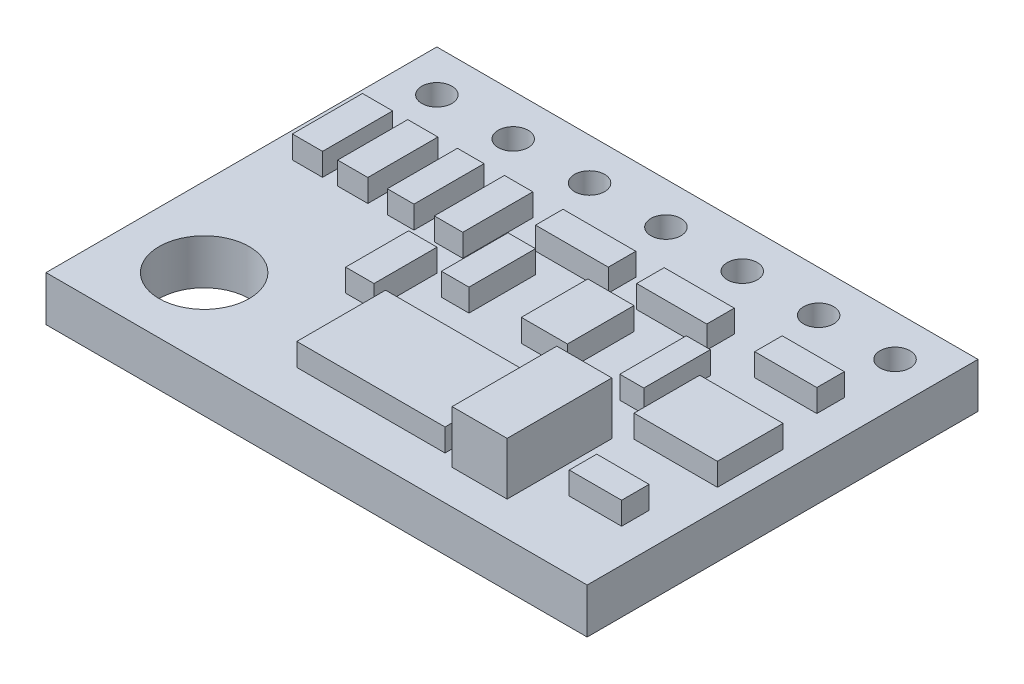
from build123d import *

# Parameters (mm, degrees)
SKETCH1_W           = 18
SKETCH1_H           = 13
SKETCH1_R           = 0.5
SKETCH1_R_2         = 1.5
BOSS_EXTRUDE1_DEPTH = 1.5
SKETCH2_W           = 1.829914293
SKETCH2_H           = 3.482740107
BOSS_EXTRUDE2_DEPTH = 1.75
SKETCH3_W           = 4.928962693
SKETCH3_H           = 2.951474666
SKETCH3_W_2         = 1.003501387
SKETCH3_H_2         = 2.331664987
SKETCH3_W_3         = 0.8854424
SKETCH3_W_4         = 0.944471893
SKETCH3_H_3         = 2.095547014
SKETCH3_W_5         = 0.914957147
SKETCH3_H_4         = 2.213606
SKETCH3_W_6         = 2.420209226
SKETCH3_H_5         = 0.914957147
SKETCH3_W_7         = 2.331664986
SKETCH3_W_8         = 2.066032267
SKETCH3_W_9         = 0.79689816
SKETCH3_W_10        = 2.774386186
SKETCH3_H_6         = 2.184091253
SKETCH3_W_11        = 1.741370054
SKETCH3_W_12        = 1.534766827
BOSS_EXTRUDE3_DEPTH = 0.75


with BuildPart() as part:
    # Sketch1 → Boss-Extrude1 (new body)
    with BuildSketch(Plane(origin=(0, 0, 0), x_dir=(1, 0, 0), z_dir=(0, 1, 0))):
        with Locations((9, -6.5)):
            Rectangle(SKETCH1_W, SKETCH1_H)
        with Locations((1.38, -1.38)):
            Circle(SKETCH1_R, mode=Mode.SUBTRACT)
        with Locations((3.92, -1.38)):
            Circle(SKETCH1_R, mode=Mode.SUBTRACT)
        with Locations((6.46, -1.38)):
            Circle(SKETCH1_R, mode=Mode.SUBTRACT)
        with Locations((9, -1.38)):
            Circle(SKETCH1_R, mode=Mode.SUBTRACT)
        with Locations((11.54, -1.38)):
            Circle(SKETCH1_R, mode=Mode.SUBTRACT)
        with Locations((14.08, -1.38)):
            Circle(SKETCH1_R, mode=Mode.SUBTRACT)
        with Locations((16.62, -1.38)):
            Circle(SKETCH1_R, mode=Mode.SUBTRACT)
        with Locations((2.63, -10.37)):
            Circle(SKETCH1_R_2, mode=Mode.SUBTRACT)
    extrude(amount=-BOSS_EXTRUDE1_DEPTH)

    # Sketch2 → Boss-Extrude2 (add)
    with BuildSketch(Plane(origin=(0, 0, 0), x_dir=(1, 0, 0), z_dir=(0, 1, 0))):
        with Locations((13.279638267, -10.115556466)):
            Rectangle(SKETCH2_W, SKETCH2_H)
    extrude(amount=BOSS_EXTRUDE2_DEPTH)

    # Sketch3 → Boss-Extrude3 (add)
    with BuildSketch(Plane(origin=(0, 0, 0), x_dir=(1, 0, 0), z_dir=(0, 1, 0))):
        with Locations((9.368934334, -10.08604172)):
            Rectangle(SKETCH3_W, SKETCH3_H)
        with Locations((1.355680614, -4.492997226)):
            Rectangle(SKETCH3_W_2, SKETCH3_H_2)
        with Locations((2.860932694, -4.492997226)):
            Rectangle(SKETCH3_W_2, SKETCH3_H_2)
        with Locations((4.454729013, -4.492997226)):
            Rectangle(SKETCH3_W_3, SKETCH3_H_2)
        with Locations((6.048525334, -4.492997226)):
            Rectangle(SKETCH3_W_4, SKETCH3_H_2)
        with Locations((6.048525334, -7.56253088)):
            Rectangle(SKETCH3_W_4, SKETCH3_H_3)
        with Locations((7.745623267, -6.027764053)):
            Rectangle(SKETCH3_W_5, SKETCH3_H_4)
        with Locations((8.73436728, -3.784643307)):
            Rectangle(SKETCH3_W_6, SKETCH3_H_5)
        with Locations((12.05477628, -3.784643307)):
            Rectangle(SKETCH3_W_7, SKETCH3_H_5)
        with Locations((15.847421227, -3.784643307)):
            Rectangle(SKETCH3_W_8, SKETCH3_H_5)
        with Locations((13.619057853, -6.027764053)):
            Rectangle(SKETCH3_W_9, SKETCH3_H_4)
        with Locations((15.965480213, -6.927963827)):
            Rectangle(SKETCH3_W_10, SKETCH3_H_6)
        with Locations((16.009752333, -10.277887574)):
            Rectangle(SKETCH3_W_11, SKETCH3_H_5)
        with Locations((10.711855307, -6.027764053)):
            Rectangle(SKETCH3_W_12, SKETCH3_H_4)
    extrude(amount=BOSS_EXTRUDE3_DEPTH)


solid = part.part
